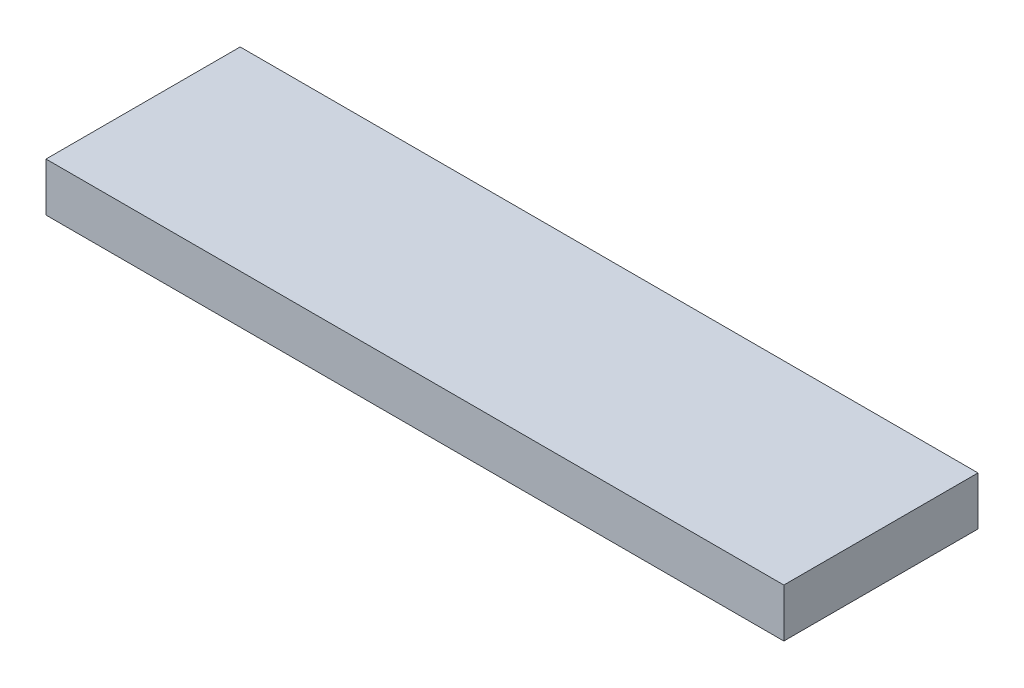
from build123d import *

# Parameters (mm, degrees)
SKETCH1_W           = 48.26
SKETCH1_H           = 12.7
BOSS_EXTRUDE1_DEPTH = 3.175


with BuildPart() as part:
    # Sketch1 → Boss-Extrude1 (new body)
    with BuildSketch(Plane(origin=(0, 0, 0), x_dir=(1, 0, 0), z_dir=(0, 1, 0))):
        Rectangle(SKETCH1_W, SKETCH1_H)
    extrude(amount=BOSS_EXTRUDE1_DEPTH)


solid = part.part
